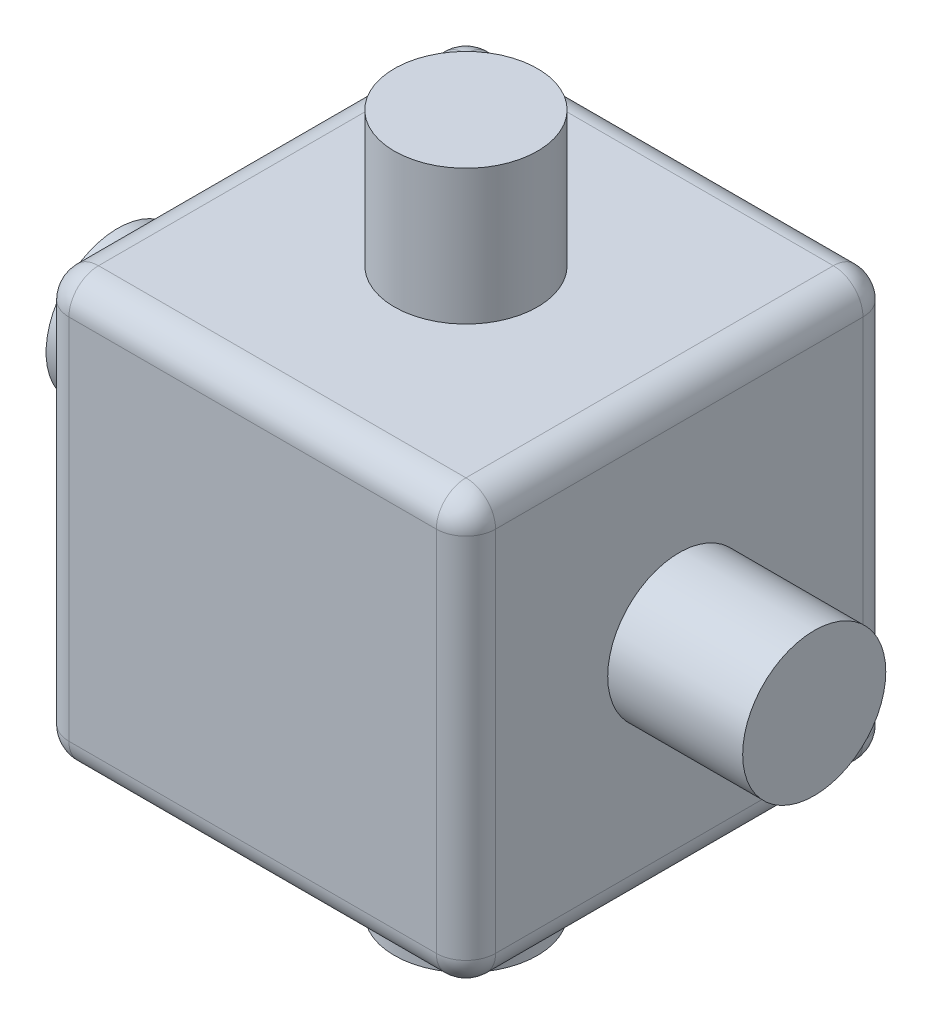
from build123d import *

# Parameters (mm, degrees)
SKETCH1_W           = 14.4
SKETCH1_H           = 14.4
BOSS_EXTRUDE1_DEPTH = 7.2
SKETCH2_R           = 2.415
BOSS_EXTRUDE2_DEPTH = 11.755
SKETCH3_R           = 2.415
BOSS_EXTRUDE3_DEPTH = 11.755
FILLET2_R           = 1


with BuildPart() as part:
    # Sketch1 → Boss-Extrude1 (new body, symmetric)
    with BuildSketch(Plane(origin=(0, 0, 0), x_dir=(1, 0, 0), z_dir=(0, 1, 0))):
        Rectangle(SKETCH1_W, SKETCH1_H)
    extrude(amount=BOSS_EXTRUDE1_DEPTH, both=True)

    # Sketch2 → Boss-Extrude2 (add, symmetric)
    with BuildSketch(Plane(origin=(0, 0, 0), x_dir=(0, 0, -1), z_dir=(1, 0, 0))):
        Circle(SKETCH2_R)
    extrude(amount=BOSS_EXTRUDE2_DEPTH, both=True)

    # Sketch3 → Boss-Extrude3 (add, symmetric)
    with BuildSketch(Plane(origin=(0, 0, 0), x_dir=(1, 0, 0), z_dir=(0, 1, 0))):
        Circle(SKETCH3_R)
    extrude(amount=BOSS_EXTRUDE3_DEPTH, both=True)

    # Fillet2
    fillet2_edges = [part.edges().sort_by_distance(p)[0] for p in [
        (-7.2, 7.2, 0),
        (0, 7.2, 7.2),
        (7.2, 7.2, 0),
        (0, -7.2, 7.2),
        (-7.2, -7.2, 0),
        (0, -7.2, -7.2),
        (7.2, -7.2, 0),
        (0, 7.2, -7.2),
        (7.2, 0, 7.2),
        (-7.2, 0, 7.2),
        (-7.2, 0, -7.2),
        (7.2, 0, -7.2),
    ]]
    fillet(fillet2_edges, radius=FILLET2_R)


solid = part.part
